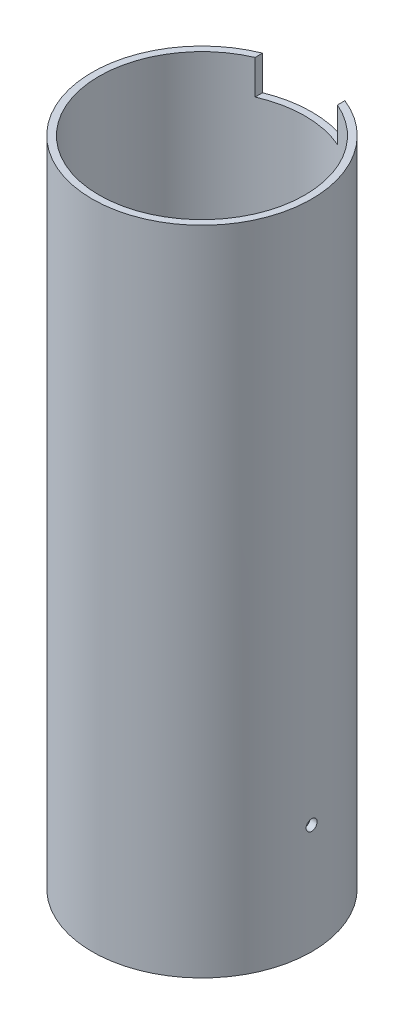
from build123d import *

# Parameters (mm, degrees)
SKETCH1_R                      = 50.8
SKETCH1_R_2                    = 47.625
EXTRUDE_THIN1_DEPTH            = 301.625
CUT_EXTRUDE1_REACH             = 52.8
SKETCH2_W                      = 38.1
SKETCH2_H                      = 31.75
CUT_EXTRUDE2_REACH             = 52.8
SKETCH3_R                      = 2.54
CUT_EXTRUDE2_DIRECTION_2_REACH = 52.8
CUT_EXTRUDE3_REACH             = 52.8
SKETCH4_R                      = 2.54


with BuildPart() as part:
    # Sketch1 → Extrude-Thin1 (new body)
    with BuildSketch(Plane(origin=(0, 0, 0), x_dir=(1, 0, 0), z_dir=(0, 1, 0))):
        Circle(SKETCH1_R)
        Circle(SKETCH1_R_2, mode=Mode.SUBTRACT)
    extrude(amount=EXTRUDE_THIN1_DEPTH)

    # Sketch2 → Cut-Extrude1 (cut, up to next)
    with BuildSketch(Plane.XY, mode=Mode.PRIVATE) as cut_extrude1_sk1:
        with Locations((0, 301.625)):
            Rectangle(SKETCH2_W, SKETCH2_H)
    cut_extrude1_tool1 = extrude(cut_extrude1_sk1.sketch, amount=-CUT_EXTRUDE1_REACH, mode=Mode.PRIVATE) & part.part
    add(cut_extrude1_tool1.solids().sort_by_distance((0, 301.625, 0))[0], mode=Mode.SUBTRACT)

    # Sketch3 → Cut-Extrude2 (cut, up to next)
    with BuildSketch(Plane(origin=(0, 0, 0), x_dir=(0, 0, -1), z_dir=(1, 0, 0)), mode=Mode.PRIVATE) as cut_extrude2_sk1:
        with Locations((0, 50.8)):
            Circle(SKETCH3_R)
    cut_extrude2_tool1 = extrude(cut_extrude2_sk1.sketch, amount=-CUT_EXTRUDE2_REACH, mode=Mode.PRIVATE) & part.part
    add(cut_extrude2_tool1.solids().sort_by_distance((0, 50.8, 0))[0], mode=Mode.SUBTRACT)

    # Sketch3 → Cut-Extrude2 direction 2 (cut, up to next)
    with BuildSketch(Plane(origin=(0, 0, 0), x_dir=(0, 0, -1), z_dir=(1, 0, 0)), mode=Mode.PRIVATE) as cut_extrude2_direction_2_sk1:
        with Locations((0, 50.8)):
            Circle(SKETCH3_R)
    cut_extrude2_direction_2_tool1 = extrude(cut_extrude2_direction_2_sk1.sketch, amount=CUT_EXTRUDE2_DIRECTION_2_REACH, mode=Mode.PRIVATE) & part.part
    add(cut_extrude2_direction_2_tool1.solids().sort_by_distance((0, 50.8, 0))[0], mode=Mode.SUBTRACT)

    # Sketch4 → Cut-Extrude3 (cut, up to next)
    with BuildSketch(Plane(origin=(0, 0, 0), x_dir=(0, 0, -1), z_dir=(1, 0, 0)), mode=Mode.PRIVATE) as cut_extrude3_sk1:
        with Locations((0, 203.2)):
            Circle(SKETCH4_R)
    cut_extrude3_tool1 = extrude(cut_extrude3_sk1.sketch, amount=-CUT_EXTRUDE3_REACH, mode=Mode.PRIVATE) & part.part
    add(cut_extrude3_tool1.solids().sort_by_distance((0, 203.2, 0))[0], mode=Mode.SUBTRACT)


solid = part.part
